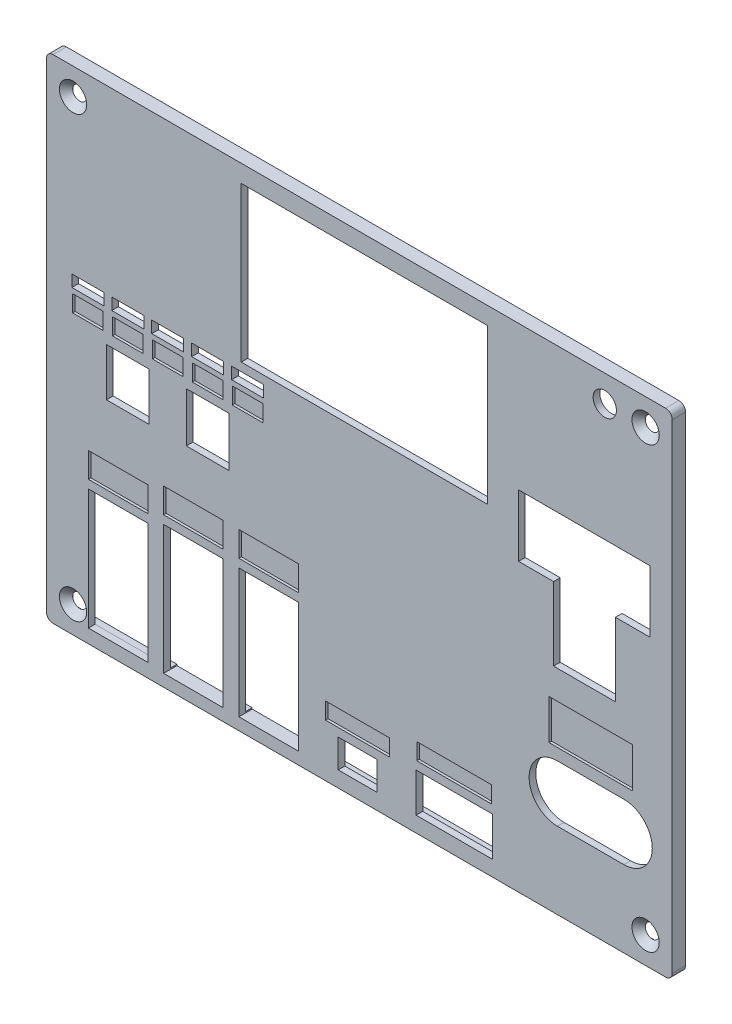
from build123d import *

# Parameters (mm, degrees)
CROQUIS1_W              = 188
CROQUIS1_H              = 148
SALIENTE_EXTRUIR1_DEPTH = 4
CROQUIS2_R              = 2.1
CORTAR_EXTRUIR1_DEPTH   = 4
REDONDEO1_R             = 2
CHAFL_N1_SIZE           = 2
CORTAR_EXTRUIR4_REACH   = 6
CROQUIS4_R              = 3.5
CROQUIS4_W              = 17.9
CROQUIS4_H              = 36.2
CROQUIS4_W_2            = 9.62
CROQUIS4_H_2            = 3.54
CROQUIS4_H_3            = 38.74
CROQUIS4_W_3            = 11.62
CROQUIS4_H_4            = 8.54
CROQUIS4_W_4            = 22.9
CROQUIS4_H_5            = 11.75
CROQUIS4_W_5            = 74
CROQUIS4_H_6            = 46.5
CROQUIS4_W_6            = 12.8
CROQUIS4_H_7            = 14.4
CROQUIS4_H_8            = 14.9
CROQUIS5_W              = 180
CROQUIS5_H              = 140
CORTAR_EXTRUIR5_DEPTH   = 2
SALIENTE_EXTRUIR4_DEPTH = 1.5
CROQUIS8_W              = 17.9
CROQUIS8_H              = 7.5
CROQUIS8_W_2            = 19.22
CROQUIS8_H_2            = 5
CROQUIS8_W_3            = 22.5
CROQUIS8_W_4            = 25
CROQUIS8_H_3            = 12
CROQUIS8_W_5            = 9.22
CROQUIS8_W_6            = 9.222831243
CORTAR_EXTRUIR6_DEPTH   = 0.75


with BuildPart() as part:
    # Croquis1 → Saliente-Extruir1 (new body)
    with BuildSketch(Plane.XY):
        with Locations((94, 74)):
            Rectangle(CROQUIS1_W, CROQUIS1_H)
    extrude(amount=SALIENTE_EXTRUIR1_DEPTH)

    # Croquis2 → Cortar-Extruir1 (cut)
    with BuildSketch(Plane(origin=(0, 0, 0), x_dir=(-1, 0, 0), z_dir=(0, 0, -1))):
        with Locations((-8, 140)):
            Circle(CROQUIS2_R)
        with Locations((-180, 140)):
            Circle(CROQUIS2_R)
        with Locations((-180, 8)):
            Circle(CROQUIS2_R)
        with Locations((-8, 8)):
            Circle(CROQUIS2_R)
    extrude(amount=-CORTAR_EXTRUIR1_DEPTH, mode=Mode.SUBTRACT)

    # Redondeo1
    redondeo1_edges = [part.edges().sort_by_distance(p)[0] for p in [
        (0, 148, 2),
        (188, 148, 2),
        (188, 0, 2),
        (0, 0, 2),
    ]]
    fillet(redondeo1_edges, radius=REDONDEO1_R)

    # Chaflán1
    chafl_n1_edges = [part.edges().sort_by_distance(p)[0] for p in [
        (10.1, 8, 4),
        (182.1, 8, 4),
        (182.1, 140, 4),
        (10.1, 140, 4),
    ]]
    chamfer(chafl_n1_edges, length=CHAFL_N1_SIZE)

    # Croquis4 → Cortar-Extruir4 (cut, up to next)
    with BuildSketch(Plane.XY.offset(4), mode=Mode.PRIVATE) as cortar_extruir4_sk1:
        with Locations((167.73, 140)):
            Circle(CROQUIS4_R)
    cortar_extruir4_tool1 = extrude(cortar_extruir4_sk1.sketch, amount=-CORTAR_EXTRUIR4_REACH, mode=Mode.PRIVATE) & part.part
    add(cortar_extruir4_tool1.solids().sort_by_distance((167.73, 140, 4))[0], mode=Mode.SUBTRACT)
    # Croquis4 → Cortar-Extruir4 (cut, up to next)
    with BuildSketch(Plane.XY.offset(4), mode=Mode.PRIVATE) as cortar_extruir4_sk2:
        with Locations((21.55, 22.21)):
            Rectangle(CROQUIS4_W, CROQUIS4_H)
    cortar_extruir4_tool2 = extrude(cortar_extruir4_sk2.sketch, amount=-CORTAR_EXTRUIR4_REACH, mode=Mode.PRIVATE) & part.part
    add(cortar_extruir4_tool2.solids().sort_by_distance((21.55, 22.21, 4))[0], mode=Mode.SUBTRACT)
    # Croquis4 → Cortar-Extruir4 (cut, up to next)
    with BuildSketch(Plane.XY.offset(4), mode=Mode.PRIVATE) as cortar_extruir4_sk3:
        with Locations((36.44, 92)):
            Rectangle(CROQUIS4_W_2, CROQUIS4_H_2)
    cortar_extruir4_tool3 = extrude(cortar_extruir4_sk3.sketch, amount=-CORTAR_EXTRUIR4_REACH, mode=Mode.PRIVATE) & part.part
    add(cortar_extruir4_tool3.solids().sort_by_distance((36.44, 92, 4))[0], mode=Mode.SUBTRACT)
    # Croquis4 → Cortar-Extruir4 (cut, up to next)
    with BuildSketch(Plane.XY.offset(4), mode=Mode.PRIVATE) as cortar_extruir4_sk4:
        with Locations((44.15, 23)):
            Rectangle(CROQUIS4_W, CROQUIS4_H_3)
    cortar_extruir4_tool4 = extrude(cortar_extruir4_sk4.sketch, amount=-CORTAR_EXTRUIR4_REACH, mode=Mode.PRIVATE) & part.part
    add(cortar_extruir4_tool4.solids().sort_by_distance((44.15, 23, 4))[0], mode=Mode.SUBTRACT)
    # Croquis4 → Cortar-Extruir4 (cut, up to next)
    with BuildSketch(Plane.XY.offset(4), mode=Mode.PRIVATE) as cortar_extruir4_sk5:
        with Locations((66.77, 23)):
            Rectangle(CROQUIS4_W, CROQUIS4_H_3)
    cortar_extruir4_tool5 = extrude(cortar_extruir4_sk5.sketch, amount=-CORTAR_EXTRUIR4_REACH, mode=Mode.PRIVATE) & part.part
    add(cortar_extruir4_tool5.solids().sort_by_distance((66.77, 23, 4))[0], mode=Mode.SUBTRACT)
    # Croquis4 → Cortar-Extruir4 (cut, up to next)
    with BuildSketch(Plane.XY.offset(4), mode=Mode.PRIVATE) as cortar_extruir4_sk6:
        with Locations((93.46, 9)):
            Rectangle(CROQUIS4_W_3, CROQUIS4_H_4)
    cortar_extruir4_tool6 = extrude(cortar_extruir4_sk6.sketch, amount=-CORTAR_EXTRUIR4_REACH, mode=Mode.PRIVATE) & part.part
    add(cortar_extruir4_tool6.solids().sort_by_distance((93.46, 9, 4))[0], mode=Mode.SUBTRACT)
    # Croquis4 → Cortar-Extruir4 (cut, up to next)
    with BuildSketch(Plane.XY.offset(4), mode=Mode.PRIVATE) as cortar_extruir4_sk7:
        with Locations((122.5, 10.525)):
            Rectangle(CROQUIS4_W_4, CROQUIS4_H_5)
    cortar_extruir4_tool7 = extrude(cortar_extruir4_sk7.sketch, amount=-CORTAR_EXTRUIR4_REACH, mode=Mode.PRIVATE) & part.part
    add(cortar_extruir4_tool7.solids().sort_by_distance((122.5, 10.525, 4))[0], mode=Mode.SUBTRACT)
    # Croquis4 → Cortar-Extruir4 (cut, up to next)
    with BuildSketch(Plane.XY.offset(4), mode=Mode.PRIVATE) as cortar_extruir4_sk8:
        with Locations((12.44, 92)):
            Rectangle(CROQUIS4_W_2, CROQUIS4_H_2)
    cortar_extruir4_tool8 = extrude(cortar_extruir4_sk8.sketch, amount=-CORTAR_EXTRUIR4_REACH, mode=Mode.PRIVATE) & part.part
    add(cortar_extruir4_tool8.solids().sort_by_distance((12.44, 92, 4))[0], mode=Mode.SUBTRACT)
    # Croquis4 → Cortar-Extruir4 (cut, up to next)
    with BuildSketch(Plane.XY.offset(4), mode=Mode.PRIVATE) as cortar_extruir4_sk9:
        with Locations((48.44, 92)):
            Rectangle(CROQUIS4_W_2, CROQUIS4_H_2)
    cortar_extruir4_tool9 = extrude(cortar_extruir4_sk9.sketch, amount=-CORTAR_EXTRUIR4_REACH, mode=Mode.PRIVATE) & part.part
    add(cortar_extruir4_tool9.solids().sort_by_distance((48.44, 92, 4))[0], mode=Mode.SUBTRACT)
    # Croquis4 → Cortar-Extruir4 (cut, up to next)
    with BuildSketch(Plane.XY.offset(4), mode=Mode.PRIVATE) as cortar_extruir4_sk10:
        with Locations((24.44, 92)):
            Rectangle(CROQUIS4_W_2, CROQUIS4_H_2)
    cortar_extruir4_tool10 = extrude(cortar_extruir4_sk10.sketch, amount=-CORTAR_EXTRUIR4_REACH, mode=Mode.PRIVATE) & part.part
    add(cortar_extruir4_tool10.solids().sort_by_distance((24.44, 92, 4))[0], mode=Mode.SUBTRACT)
    # Croquis4 → Cortar-Extruir4 (cut, up to next)
    with BuildSketch(Plane.XY.offset(4), mode=Mode.PRIVATE) as cortar_extruir4_sk11:
        with Locations((60.44, 92)):
            Rectangle(CROQUIS4_W_2, CROQUIS4_H_2)
    cortar_extruir4_tool11 = extrude(cortar_extruir4_sk11.sketch, amount=-CORTAR_EXTRUIR4_REACH, mode=Mode.PRIVATE) & part.part
    add(cortar_extruir4_tool11.solids().sort_by_distance((60.44, 92, 4))[0], mode=Mode.SUBTRACT)
    # Croquis4 → Cortar-Extruir4 (cut, up to next)
    with BuildSketch(Plane.XY.offset(4), mode=Mode.PRIVATE) as cortar_extruir4_sk12:
        with Locations((95.52, 119.5)):
            Rectangle(CROQUIS4_W_5, CROQUIS4_H_6)
    cortar_extruir4_tool12 = extrude(cortar_extruir4_sk12.sketch, amount=-CORTAR_EXTRUIR4_REACH, mode=Mode.PRIVATE) & part.part
    add(cortar_extruir4_tool12.solids().sort_by_distance((95.52, 119.5, 4))[0], mode=Mode.SUBTRACT)
    # Croquis4 → Cortar-Extruir4 (cut, up to next)
    with BuildSketch(Plane.XY.offset(4), mode=Mode.PRIVATE) as cortar_extruir4_sk13:
        with Locations((24.425, 73.4)):
            Rectangle(CROQUIS4_W_6, CROQUIS4_H_7)
    cortar_extruir4_tool13 = extrude(cortar_extruir4_sk13.sketch, amount=-CORTAR_EXTRUIR4_REACH, mode=Mode.PRIVATE) & part.part
    add(cortar_extruir4_tool13.solids().sort_by_distance((24.425, 73.4, 4))[0], mode=Mode.SUBTRACT)
    # Croquis4 → Cortar-Extruir4 (cut, up to next)
    with BuildSketch(Plane.XY.offset(4), mode=Mode.PRIVATE) as cortar_extruir4_sk14:
        with Locations((48.425, 73.65)):
            Rectangle(CROQUIS4_W_6, CROQUIS4_H_8)
    cortar_extruir4_tool14 = extrude(cortar_extruir4_sk14.sketch, amount=-CORTAR_EXTRUIR4_REACH, mode=Mode.PRIVATE) & part.part
    add(cortar_extruir4_tool14.solids().sort_by_distance((48.425, 73.65, 4))[0], mode=Mode.SUBTRACT)
    # Croquis4 → Cortar-Extruir4 (cut, up to next)
    with BuildSketch(Plane.XY.offset(4), mode=Mode.PRIVATE) as cortar_extruir4_sk15:
        Polygon((141.84, 104.68), (181.39, 104.68), (181.39, 86.08), (170.94, 86.08), (170.94, 64.08), (152.34, 64.08), (152.34, 86.08), (141.84, 86.08), align=None)
    cortar_extruir4_tool15 = extrude(cortar_extruir4_sk15.sketch, amount=-CORTAR_EXTRUIR4_REACH, mode=Mode.PRIVATE) & part.part
    add(cortar_extruir4_tool15.solids().sort_by_distance((161.623936, 88.12411, 4))[0], mode=Mode.SUBTRACT)
    # Croquis4 → Cortar-Extruir4 (cut, up to next)
    with BuildSketch(Plane.XY.offset(4), mode=Mode.PRIVATE) as cortar_extruir4_sk16:
        with BuildLine():
            Line((153.5, 40), (173.5, 40))
            ThreePointArc((173.5, 40), (182, 31.5), (173.5, 23))
            Line((173.5, 23), (153.5, 23))
            ThreePointArc((153.5, 23), (145, 31.5), (153.5, 40))
        make_face()
    cortar_extruir4_tool16 = extrude(cortar_extruir4_sk16.sketch, amount=-CORTAR_EXTRUIR4_REACH, mode=Mode.PRIVATE) & part.part
    add(cortar_extruir4_tool16.solids().sort_by_distance((163.5, 31.5, 4))[0], mode=Mode.SUBTRACT)

    # Croquis5 → Cortar-Extruir5 (cut)
    with BuildSketch(Plane(origin=(0, 0, 0), x_dir=(-1, 0, 0), z_dir=(0, 0, -1))):
        with Locations((-94, 74)):
            Rectangle(CROQUIS5_W, CROQUIS5_H)
    extrude(amount=-CORTAR_EXTRUIR5_DEPTH, mode=Mode.SUBTRACT)

    # Croquis7 → Saliente-Extruir4 (add)
    with BuildSketch(Plane(origin=(0, 0, 0), x_dir=(-1, 0, 0), z_dir=(0, 0, -1))):
        with BuildLine():
            Line((-186.5, 61.5), (-186.5, 86.5))
            ThreePointArc((-186.5, 86.5), (-186, 87), (-185.5, 86.5))
            Line((-185.5, 86.5), (-185.5, 61.5))
            ThreePointArc((-185.5, 61.5), (-186, 61), (-186.5, 61.5))
        make_face()
        with BuildLine():
            Line((-2.5, 61.5), (-2.5, 86.5))
            ThreePointArc((-2.5, 86.5), (-2, 87), (-1.5, 86.5))
            Line((-1.5, 86.5), (-1.5, 61.5))
            ThreePointArc((-1.5, 61.5), (-2, 61), (-2.5, 61.5))
        make_face()
    extrude(amount=SALIENTE_EXTRUIR4_DEPTH)

    # Croquis8 → Cortar-Extruir6 (cut)
    with BuildSketch(Plane.XY.offset(4)):
        with Locations((21.55, 46.56)):
            Rectangle(CROQUIS8_W, CROQUIS8_H)
        with Locations((44.15, 48.62)):
            Rectangle(CROQUIS8_W, CROQUIS8_H)
        with Locations((66.77, 48.62)):
            Rectangle(CROQUIS8_W, CROQUIS8_H)
        with Locations((93.46, 18.27)):
            Rectangle(CROQUIS8_W_2, CROQUIS8_H_2)
        with Locations((122.5, 21.4)):
            Rectangle(CROQUIS8_W_3, CROQUIS8_H_2)
        with Locations((163.5, 49.5)):
            Rectangle(CROQUIS8_W_4, CROQUIS8_H_3)
        with Locations((12.44, 86.23)):
            Rectangle(CROQUIS8_W_5, CROQUIS8_H_2)
        with Locations((24.44, 86.23)):
            Rectangle(CROQUIS8_W_5, CROQUIS8_H_2)
        with Locations((36.441415621, 86.23)):
            Rectangle(CROQUIS8_W_6, CROQUIS8_H_2)
        with Locations((48.44, 86.23)):
            Rectangle(CROQUIS8_W_5, CROQUIS8_H_2)
        with Locations((60.44, 86.23)):
            Rectangle(CROQUIS8_W_5, CROQUIS8_H_2)
    extrude(amount=-CORTAR_EXTRUIR6_DEPTH, mode=Mode.SUBTRACT)


solid = part.part
